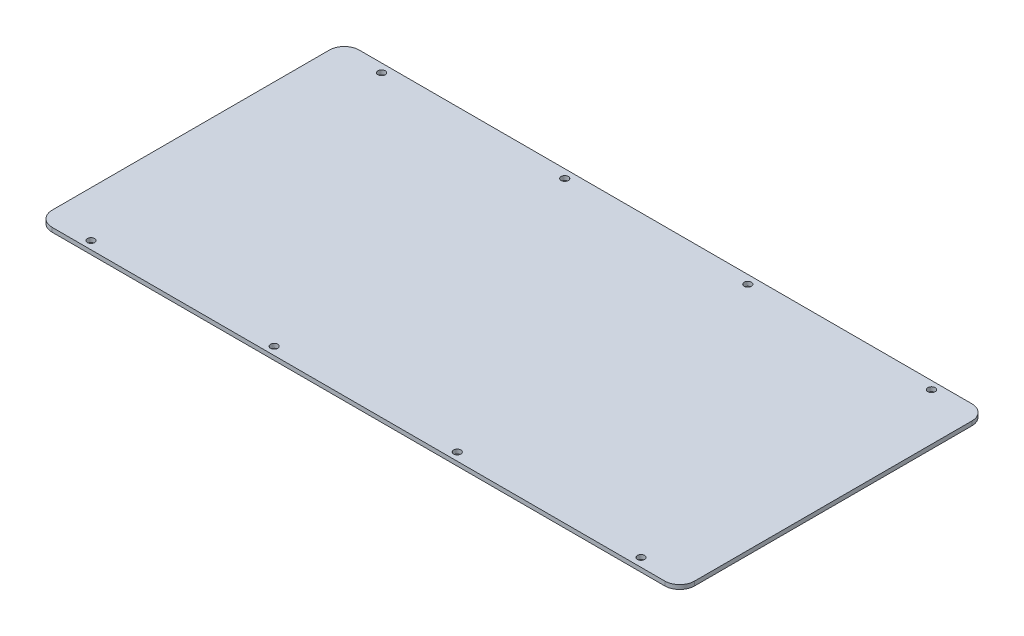
from build123d import *

# Parameters (mm, degrees)
SKETCH1_W           = 350
SKETCH1_H           = 250
BOSS_EXTRUDE1_DEPTH = 2
SKETCH4_OUTSIDE_W   = 438.024
SKETCH4_OUTSIDE_H   = 338.024
SKETCH4_OUTSIDE_R   = 1.7
CUT_EXTRUDE1_DEPTH  = 2


with BuildPart() as part:
    # Sketch1 → Boss-Extrude1 (new body)
    with BuildSketch(Plane(origin=(0, 0, 0), x_dir=(1, 0, 0), z_dir=(0, 1, 0))):
        with Locations((175, 125)):
            Rectangle(SKETCH1_W, SKETCH1_H)
    extrude(amount=BOSS_EXTRUDE1_DEPTH)

    # Sketch4 outside → Cut-Extrude1 (cut)
    with BuildSketch(Plane(origin=(0, 2, 0), x_dir=(1, 0, 0), z_dir=(0, 1, 0))):
        with Locations((175, 125)):
            Rectangle(SKETCH4_OUTSIDE_W, SKETCH4_OUTSIDE_H)
        with BuildLine():
            Line((26.493493562, 73.746405702), (26.493493562, 203.945865702))
            ThreePointArc((26.493493562, 203.945865702), (28.543746093, 208.895613171), (33.493493562, 210.945865702))
            Line((33.493493562, 210.945865702), (321.192843562, 210.945865702))
            ThreePointArc((321.192843562, 210.945865702), (326.14259103, 208.895613171), (328.192843562, 203.945865702))
            Line((328.192843562, 203.945865702), (328.192843562, 73.746405702))
            ThreePointArc((328.192843562, 73.746405702), (326.14259103, 68.796658234), (321.192843562, 66.746405702))
            Line((321.192843562, 66.746405702), (33.493493562, 66.746405702))
            ThreePointArc((33.493493562, 66.746405702), (28.543746093, 68.796658234), (26.493493562, 73.746405702))
        make_face(mode=Mode.SUBTRACT)
        with Locations((305.993493562, 70.746405702)):
            Circle(SKETCH4_OUTSIDE_R)
        with Locations((219.993493562, 70.496405702)):
            Circle(SKETCH4_OUTSIDE_R)
        with Locations((47.993493562, 70.496405702)):
            Circle(SKETCH4_OUTSIDE_R)
        with Locations((133.993493562, 70.496405702)):
            Circle(SKETCH4_OUTSIDE_R)
        with Locations((305.993493562, 207.195865702)):
            Circle(SKETCH4_OUTSIDE_R)
        with Locations((219.993493562, 206.945865702)):
            Circle(SKETCH4_OUTSIDE_R)
        with Locations((47.993493562, 206.945865702)):
            Circle(SKETCH4_OUTSIDE_R)
        with Locations((133.993493562, 206.945865702)):
            Circle(SKETCH4_OUTSIDE_R)
    extrude(amount=-CUT_EXTRUDE1_DEPTH, mode=Mode.SUBTRACT)


solid = part.part
